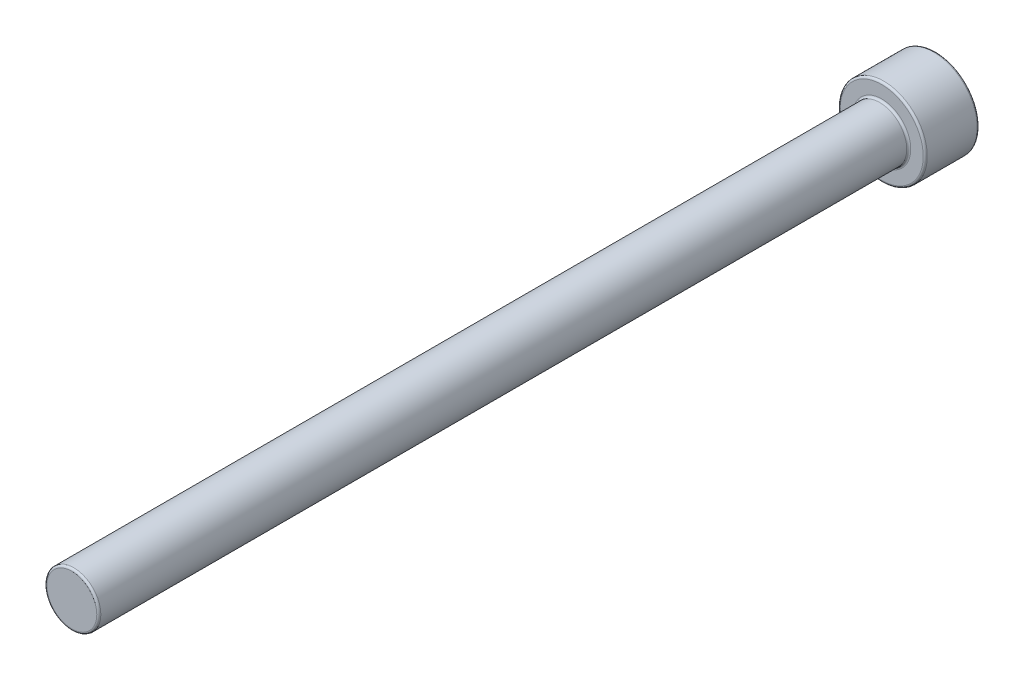
from build123d import *

# Parameters (mm, degrees)
SKETCH_1_R          = 4
EXTRUDE_1_DEPTH     = 120
SKETCH_3_R          = 6.45
EXTRUDE_2_DEPTH     = 8
CUT_EXTRUDE_1_DEPTH = 5
FILLET_1_R          = 0.3


with BuildPart() as part:
    # Эскиз1 → Бобышка-Вытянуть1 (new body)
    with BuildSketch(Plane.XY):
        Circle(SKETCH_1_R)
    extrude(amount=EXTRUDE_1_DEPTH)

    # Эскиз3 → Бобышка-Вытянуть2 (add)
    with BuildSketch(Plane(origin=(0, 0, 0), x_dir=(-1, 0, 0), z_dir=(0, 0, -1))):
        Circle(SKETCH_3_R)
    extrude(amount=EXTRUDE_2_DEPTH)

    # Эскиз4 → Вырез-Вытянуть1 (cut)
    with BuildSketch(Plane(origin=(0, 0, -8), x_dir=(-1, 0, 0), z_dir=(0, 0, -1))):
        Polygon((-3.464101615, 0), (-1.732050808, -3), (1.732050808, -3), (3.464101615, 0), (1.732050808, 3), (-1.732050808, 3), align=None)
    extrude(amount=-CUT_EXTRUDE_1_DEPTH, mode=Mode.SUBTRACT)

    # Скругление1
    fillet_1_edges = [part.edges().sort_by_distance(p)[0] for p in [
        (2.598076211, 1.5, -3),
        (0, 3, -3),
        (-2.598076211, 1.5, -3),
        (-2.598076211, -1.5, -3),
        (0, -3, -3),
        (2.598076211, -1.5, -3),
        (2.598076211, 1.5, -8),
        (2.598076211, -1.5, -8),
        (0, -3, -8),
        (-2.598076211, -1.5, -8),
        (-2.598076211, 1.5, -8),
        (0, 3, -8),
        (-4, 0, 120),
        (-4, 0, 0),
        (6.45, 0, 0),
        (6.45, 0, -8),
    ]]
    fillet(fillet_1_edges, radius=FILLET_1_R)


solid = part.part
